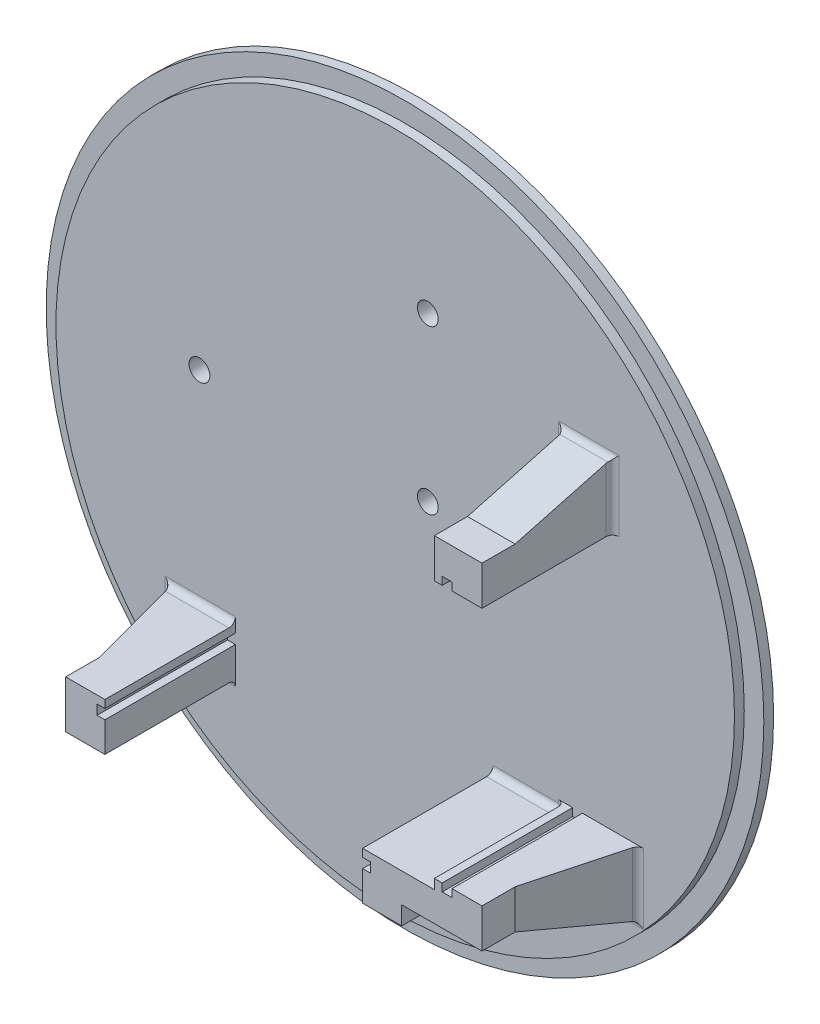
from build123d import *

# Parameters (mm, degrees)
SKIZZE1_R                       = 52
AUFSATZ_LINEAR_AUSTRAGEN1_DEPTH = 3
SKIZZE1_3_R                     = 55
SKIZZE1_3_R_2                   = 52
AUFSATZ_LINEAR_AUSTRAGEN2_DEPTH = 1.5
AUFSATZ_LINEAR_AUSTRAGEN5_DEPTH = 20
FASE2_SIZE                      = 4
FASE2_SIZE2                     = 14.92820323
FASE3_SIZE                      = 4
FASE3_SIZE2                     = 14.92820323
VERRUNDUNG1_R                   = 1
SCHNITT_LINEAR_AUSTRAGEN1_REACH = 82.312
SKIZZE3_R                       = 1.6


with BuildPart() as part:
    # Skizze1 → Aufsatz-Linear austragen1 (new body)
    with BuildSketch(Plane.XY):
        Circle(SKIZZE1_R)
    extrude(amount=AUFSATZ_LINEAR_AUSTRAGEN1_DEPTH)

    # Skizze1_3 → Aufsatz-Linear austragen2 (add)
    with BuildSketch(Plane.XY):
        Circle(SKIZZE1_3_R)
        Circle(SKIZZE1_3_R_2, mode=Mode.SUBTRACT)
    extrude(amount=AUFSATZ_LINEAR_AUSTRAGEN2_DEPTH)

    # Skizze2 → Aufsatz-Linear austragen5 (add)
    with BuildSketch(Plane.XY.offset(3)):
        Polygon((26, 21), (26, 15), (27.2, 15), (27.2, 16.2), (28.7, 16.2), (28.7, 15), (33.3, 15), (33.3, 21), align=None)
        Polygon((33.3, -30.5), (33.3, -24.5), (28.7, -24.5), (28.7, -25.7), (27.2, -25.7), (27.2, -24.5), (26, -24.5), (26, -26), (15, -26), (15, -27.2), (16.2, -27.2), (16.2, -28.7), (15, -28.7), (15, -33.3), (21, -33.3), (21, -30.5), align=None)
        Polygon((-30.5, -26), (-30.5, -33.3), (-24.5, -33.3), (-24.5, -28.7), (-25.7, -28.7), (-25.7, -27.2), (-24.5, -27.2), (-24.5, -26), align=None)
    extrude(amount=AUFSATZ_LINEAR_AUSTRAGEN5_DEPTH)

    # Fase2
    fase2_edges = [part.edges().sort_by_distance(p)[0] for p in [
        (33.3, -27.5, 3),
        (18, -33.3, 3),
        (29.65, 21, 3),
        (-30.5, -29.65, 3),
    ]]
    fase2_side = [part.faces().sort_by_distance(p)[0] for p in [
        (-0.31627578, 0.425239539, 3),
    ]]
    chamfer(fase2_edges, length=FASE2_SIZE, length2=FASE2_SIZE2, reference=fase2_side[0])

    # Fase3
    fase3_edges = [part.edges().sort_by_distance(p)[0] for p in [
        (29.15, -30.5, 3),
        (21, -33.9, 3),
    ]]
    fase3_side = [part.faces().sort_by_distance(p)[0] for p in [
        (-0.466268066, 0.638295482, 3),
    ]]
    chamfer(fase3_edges, length=FASE3_SIZE, length2=FASE3_SIZE2, reference=fase3_side[0])

    # Verrundung1
    verrundung1_edges = [part.edges().sort_by_distance(p)[0] for p in [
        (26, 20, 3),
        (29.65, 25, 3),
        (33.3, 20, 3),
        (-29.5, -33.3, 3),
        (-34.5, -29.65, 3),
        (-29.5, -26, 3),
        (26, -25.25, 3),
        (20.5, -26, 3),
        (37.3, -29.5, 3),
        (31.15, -34.5, 3),
        (25, -35.9, 3),
        (20, -37.3, 3),
    ]]
    fillet(verrundung1_edges, radius=VERRUNDUNG1_R)

    # Skizze3 → Schnitt-Linear austragen1 (cut, up to next)
    with BuildSketch(Plane.XY.offset(3), mode=Mode.PRIVATE) as schnitt_linear_austragen1_sk1:
        with Locations((4.995000167, 4.995918163)):
            Circle(SKIZZE3_R)
    schnitt_linear_austragen1_tool1 = extrude(schnitt_linear_austragen1_sk1.sketch, amount=-SCHNITT_LINEAR_AUSTRAGEN1_REACH, mode=Mode.PRIVATE) & part.part
    # Skizze3 → Schnitt-Linear austragen1 (cut, up to next)
    with BuildSketch(Plane.XY.offset(3), mode=Mode.PRIVATE) as schnitt_linear_austragen1_sk2:
        with Locations((4.995000167, 29.995918163)):
            Circle(SKIZZE3_R)
    schnitt_linear_austragen1_tool2 = extrude(schnitt_linear_austragen1_sk2.sketch, amount=-SCHNITT_LINEAR_AUSTRAGEN1_REACH, mode=Mode.PRIVATE) & part.part
    # Skizze3 → Schnitt-Linear austragen1 (cut, up to next)
    with BuildSketch(Plane.XY.offset(3), mode=Mode.PRIVATE) as schnitt_linear_austragen1_sk3:
        with Locations((-30.004999833, 4.995918163)):
            Circle(SKIZZE3_R)
    schnitt_linear_austragen1_tool3 = extrude(schnitt_linear_austragen1_sk3.sketch, amount=-SCHNITT_LINEAR_AUSTRAGEN1_REACH, mode=Mode.PRIVATE) & part.part
    add(schnitt_linear_austragen1_tool1.solids().sort_by_distance((4.995, 4.995918, 3))[0], mode=Mode.SUBTRACT)
    add(schnitt_linear_austragen1_tool2.solids().sort_by_distance((4.995, 29.995918, 3))[0], mode=Mode.SUBTRACT)
    add(schnitt_linear_austragen1_tool3.solids().sort_by_distance((-30.005, 4.995918, 3))[0], mode=Mode.SUBTRACT)


solid = part.part
